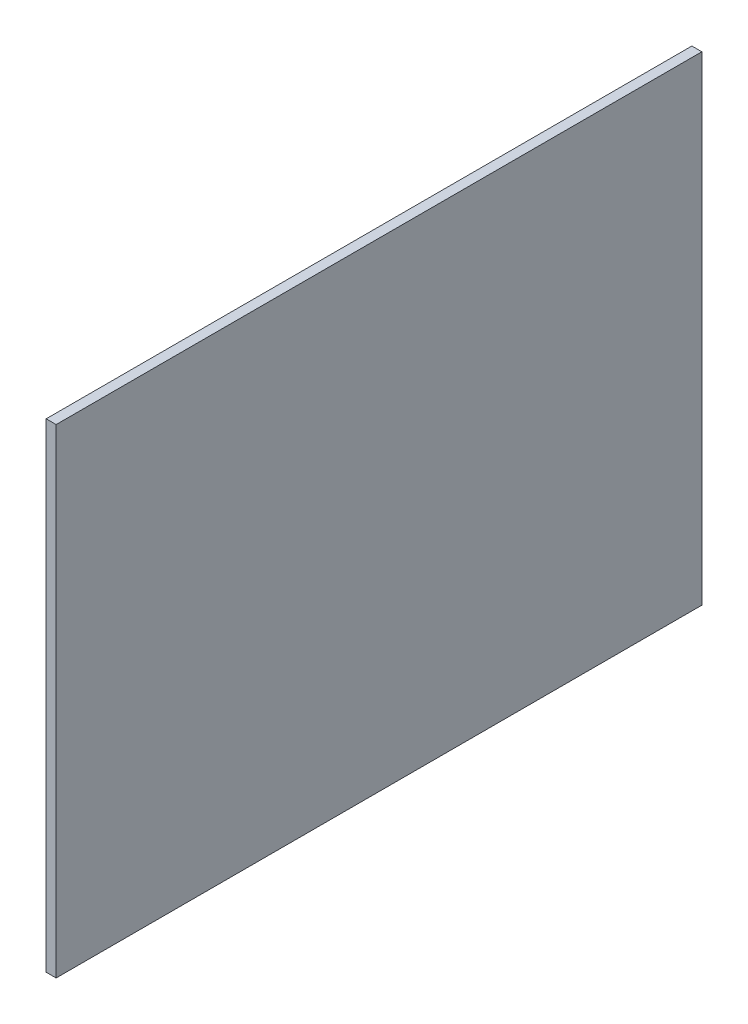
from build123d import *

# Parameters (mm, degrees)
SKETCH1_W           = 194
SKETCH1_H           = 144
BOSS_EXTRUDE1_DEPTH = 3


with BuildPart() as part:
    # Sketch1 → Boss-Extrude1 (new body)
    with BuildSketch(Plane(origin=(0, 0, 0), x_dir=(0, 0, -1), z_dir=(1, 0, 0))):
        Rectangle(SKETCH1_W, SKETCH1_H)
    extrude(amount=BOSS_EXTRUDE1_DEPTH)


solid = part.part
